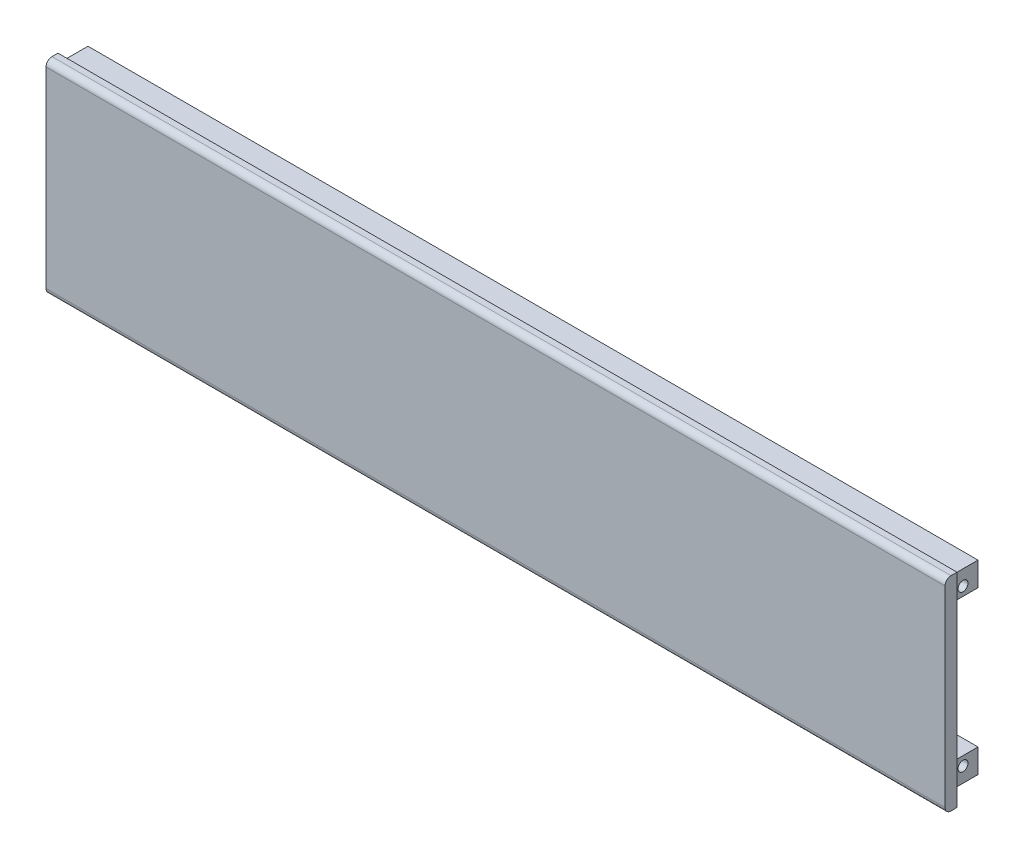
from build123d import *

# Parameters (mm, degrees)
SKETCH_1_W          = 4
SKETCH_1_H          = 68
EXTRUDE_1_DEPTH     = 300
FILLET_1_R          = 2
SKETCH_2_W          = 300
SKETCH_2_H          = 8
EXTRUDE_2_DEPTH     = 10
HOLE_WIZARD_M4_1_D  = 3.3
SKETCH_5_W          = 3
SKETCH_5_H          = 10
CUT_EXTRUDE_1_DEPTH = 62


with BuildPart() as part:
    # 草圖1 → 填料-伸長1 (new body)
    with BuildSketch(Plane(origin=(0, 0, 0), x_dir=(0, 0, -1), z_dir=(1, 0, 0))):
        Rectangle(SKETCH_1_W, SKETCH_1_H)
    extrude(amount=EXTRUDE_1_DEPTH)

    # 圓角1
    fillet_1_edges = [part.edges().sort_by_distance(p)[0] for p in [
        (150, -34, 2),
        (150, 34, 2),
    ]]
    fillet(fillet_1_edges, radius=FILLET_1_R)

    # 草圖2 → 填料-伸長2 (add)
    with BuildSketch(Plane(origin=(0, 0, -2), x_dir=(-1, 0, 0), z_dir=(0, 0, -1))):
        with Locations((-150, 27)):
            Rectangle(SKETCH_2_W, SKETCH_2_H)
        with Locations((-150, -27)):
            Rectangle(SKETCH_2_W, SKETCH_2_H)
    extrude(amount=EXTRUDE_2_DEPTH)

    # M4  螺絲攻的螺孔鑽1 (through all)
    with Locations(Plane(origin=(300, 0, 0), x_dir=(0, 0, -1), z_dir=(1, 0, 0))):
        with Locations((7, 26), (7, -26)):
            Hole(HOLE_WIZARD_M4_1_D / 2)

    # 草圖5 → 除料-伸長1 (cut)
    with BuildSketch(Plane(origin=(0, 31, 0), x_dir=(1, 0, 0), z_dir=(0, 1, 0))):
        with Locations((298.5, 7)):
            Rectangle(SKETCH_5_W, SKETCH_5_H)
    extrude(amount=-CUT_EXTRUDE_1_DEPTH, mode=Mode.SUBTRACT)


solid = part.part
